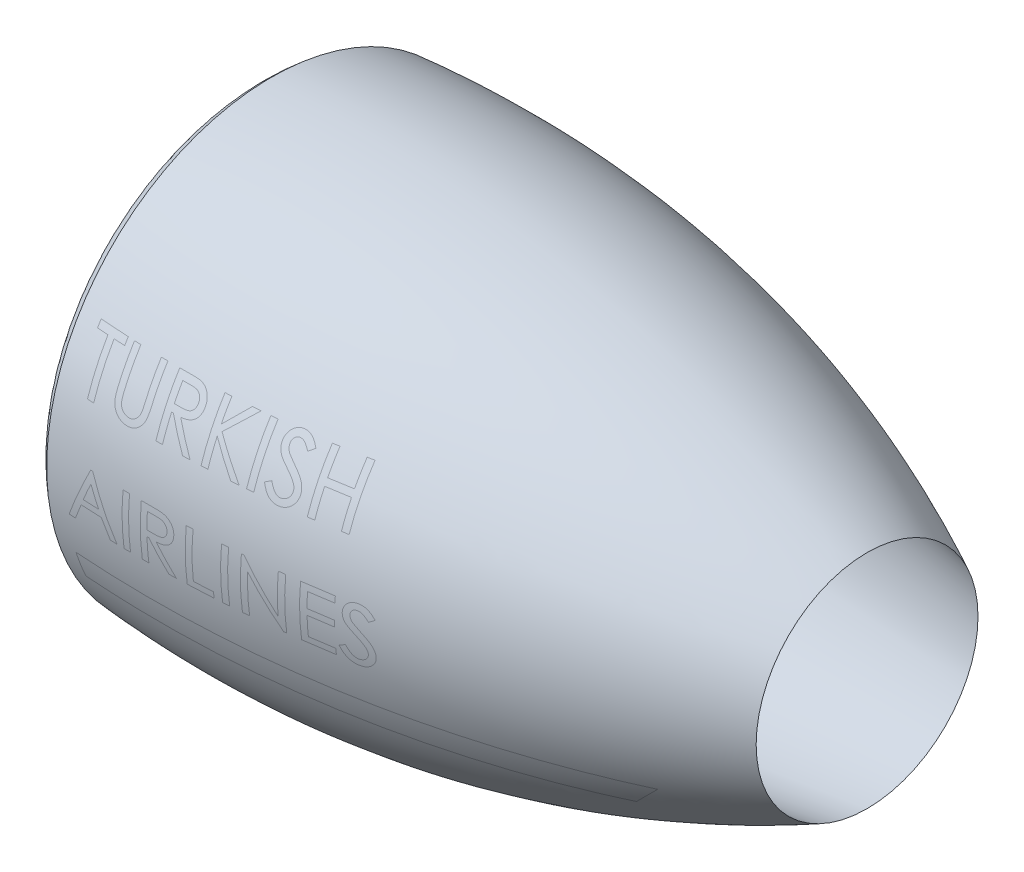
from build123d import *


with BuildPart() as part:
    # Sketch1 → Revolve1 (revolve)
    with BuildSketch(Plane.XY):
        with BuildLine():
            Line((0, 180), (25, 180))
            Line((25, 180), (34.619512209, 190))
            Line((34.619512209, 190), (59.619512209, 190))
            Line((59.619512209, 190), (580, 108))
            add(Edge.make_bspline(
                [(0, 218.810936871), (307.311613767, 244.48397788), (580, 108)],
                knots=[0, 0, 0, 1, 1, 1], degree=2))
            add(Edge.make_bspline(
                [(0, 218.810936871), (-34.080366536, 190.615967809), (0, 180)],
                knots=[0, 0, 0, 1, 1, 1], degree=2))
        make_face()
    revolve(axis=Axis((650.358266609, 0, 0), (-1, 0, 0)))


solid = part.part
